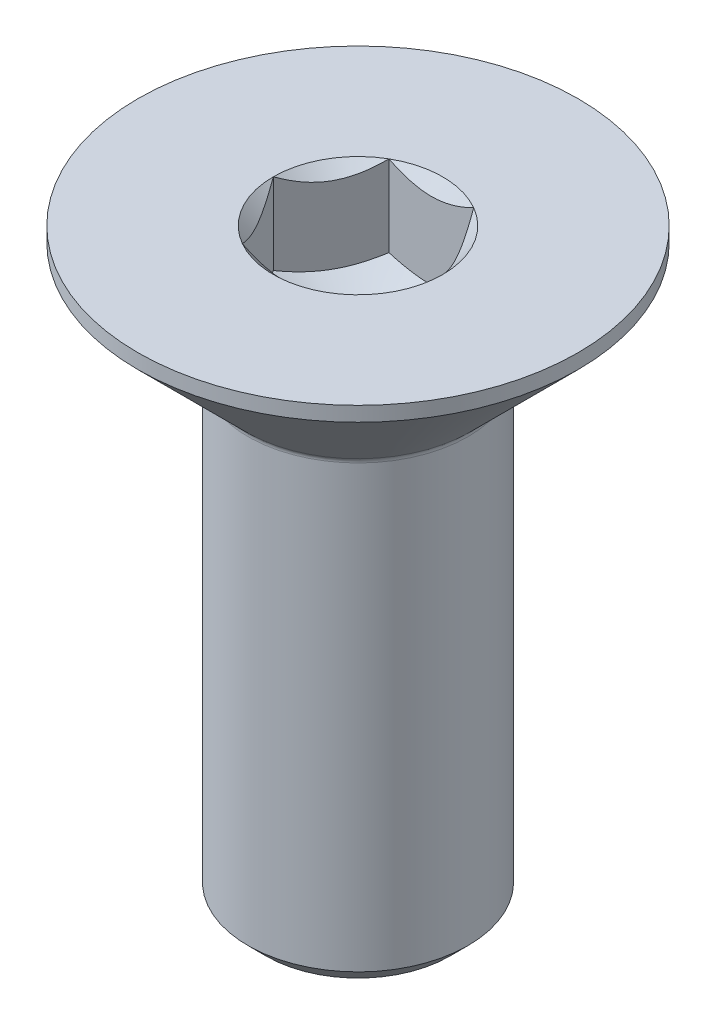
from build123d import *

# Parameters (mm, degrees)
CORTE_EXTRUS_O1_REACH = 11.055


with BuildPart() as part:
    # Esboço1 → Revolução1 (revolve)
    with BuildSketch(Plane.XY):
        with BuildLine():
            Line((0, -1.800860619), (1, -1.2))
            Line((1, -1.2), (1, 0))
            Line((1, 0), (3, 0))
            Line((3, 0), (3, -0.2))
            Line((3, -0.2), (1.529289322, -1.670710678))
            ThreePointArc((1.529289322, -1.670710678), (1.507612047, -1.703153013), (1.5, -1.741421356))
            Line((1.5, -1.741421356), (1.5, -7.75))
            Line((1.5, -7.75), (1.25, -8))
            Line((1.25, -8), (0, -8))
            Line((0, -8), (0, -1.800860619))
        make_face()
    revolve(axis=Axis((0, -1000, 0), (0, 1, 0)))

    # Corte-extrusão1: up to this cone (the profile starts inside it)
    corte_extrus_o1_end = Plane(origin=(0, 0, 0), z_dir=(0, 1, 0)).offset(-1.800859619) * Cone(1.664e-06, 27.215955714, 16.352994998, align=(Align.CENTER, Align.CENTER, Align.MIN), mode=Mode.PRIVATE)
    # Esboço2 → Corte-extrusão1 (cut, up to the surface)
    with BuildSketch(Plane(origin=(0, 0, 0), x_dir=(1, 0, 0), z_dir=(0, 1, 0)), mode=Mode.PRIVATE) as corte_extrus_o1_sk1:
        Polygon((-1.154700538, 0), (-0.577350269, -1), (0.577350269, -1), (1.154700538, 0), (0.577350269, 1), (-0.577350269, 1), align=None)
    corte_extrus_o1_tool1 = extrude(corte_extrus_o1_sk1.sketch, amount=-CORTE_EXTRUS_O1_REACH, mode=Mode.PRIVATE) & corte_extrus_o1_end
    add(corte_extrus_o1_tool1.solids().sort_by_distance((0, 0, 0))[0], mode=Mode.SUBTRACT)

    # Esboço3 → Corte-Revolução1 (revolve, cut)
    with BuildSketch(Plane.XY, mode=Mode.PRIVATE) as corte_revolu_o1_sk:
        Polygon((1.154700538, 0), (0, -1.154700538), (0, 0), align=None)
    revolve(corte_revolu_o1_sk.sketch.rotate(Axis((0, -1000, 0), (0, 1, 0)), 180), axis=Axis((0, -1000, 0), (0, 1, 0)), mode=Mode.SUBTRACT)


solid = part.part
